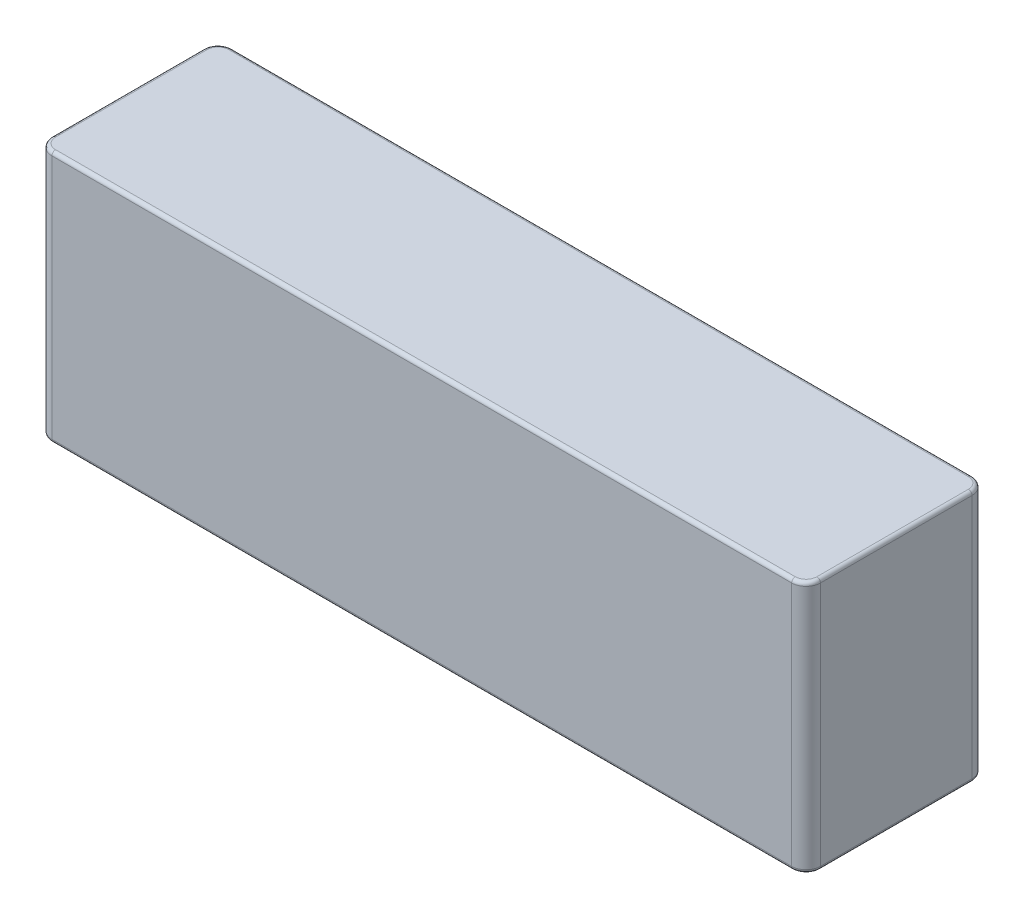
from build123d import *

# Parameters (mm, degrees)
SKETCH1_W           = 106.5
SKETCH1_H           = 35
BOSS_EXTRUDE1_DEPTH = 25
FILLET1_R           = 2
FILLET2_R           = 0.5


with BuildPart() as part:
    # Sketch1 → Boss-Extrude1 (new body)
    with BuildSketch(Plane.XY):
        Rectangle(SKETCH1_W, SKETCH1_H)
    extrude(amount=BOSS_EXTRUDE1_DEPTH)

    # Fillet1
    fillet1_edges = [part.edges().sort_by_distance(p)[0] for p in [
        (-53.25, 0, 25),
        (53.25, 0, 25),
        (-53.25, 0, 0),
        (53.25, 0, 0),
    ]]
    fillet(fillet1_edges, radius=FILLET1_R)

    # Fillet2
    fillet2_edges = [part.edges().sort_by_distance(p)[0] for p in [
        (-53.25, -17.5, 12.5),
        (-53.25, 17.5, 12.5),
        (0, -17.5, 0),
        (53.25, -17.5, 12.5),
        (0, -17.5, 25),
        (52.664213562, -17.5, 0.585786438),
        (52.664213562, -17.5, 24.414213562),
        (-52.664213562, -17.5, 24.414213562),
        (-52.664213562, -17.5, 0.585786438),
        (0, 17.5, 0),
        (0, 17.5, 25),
        (53.25, 17.5, 12.5),
        (52.664213562, 17.5, 0.585786438),
        (52.664213562, 17.5, 24.414213562),
        (-52.664213562, 17.5, 24.414213562),
        (-52.664213562, 17.5, 0.585786438),
    ]]
    fillet(fillet2_edges, radius=FILLET2_R)


solid = part.part
